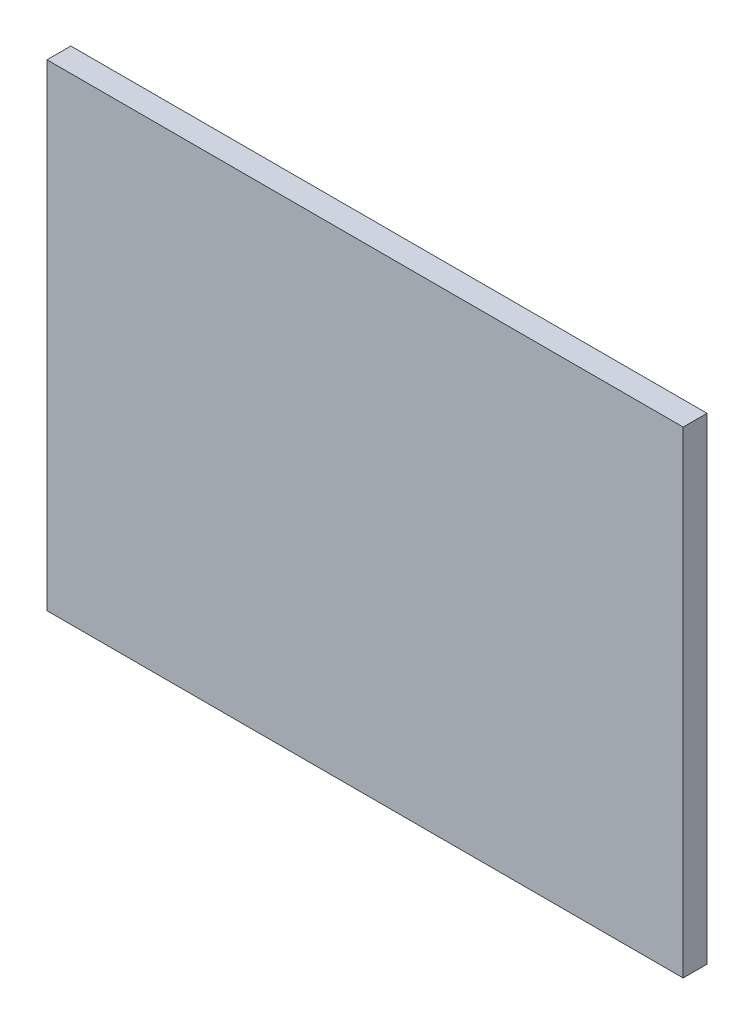
from build123d import *

# Parameters (mm, degrees)
SKETCH1_W           = 101.6
SKETCH1_H           = 76.2
BOSS_EXTRUDE1_DEPTH = 3.81


with BuildPart() as part:
    # Sketch1 → Boss-Extrude1 (new body)
    with BuildSketch(Plane.XY):
        Rectangle(SKETCH1_W, SKETCH1_H)
    extrude(amount=BOSS_EXTRUDE1_DEPTH)


solid = part.part
